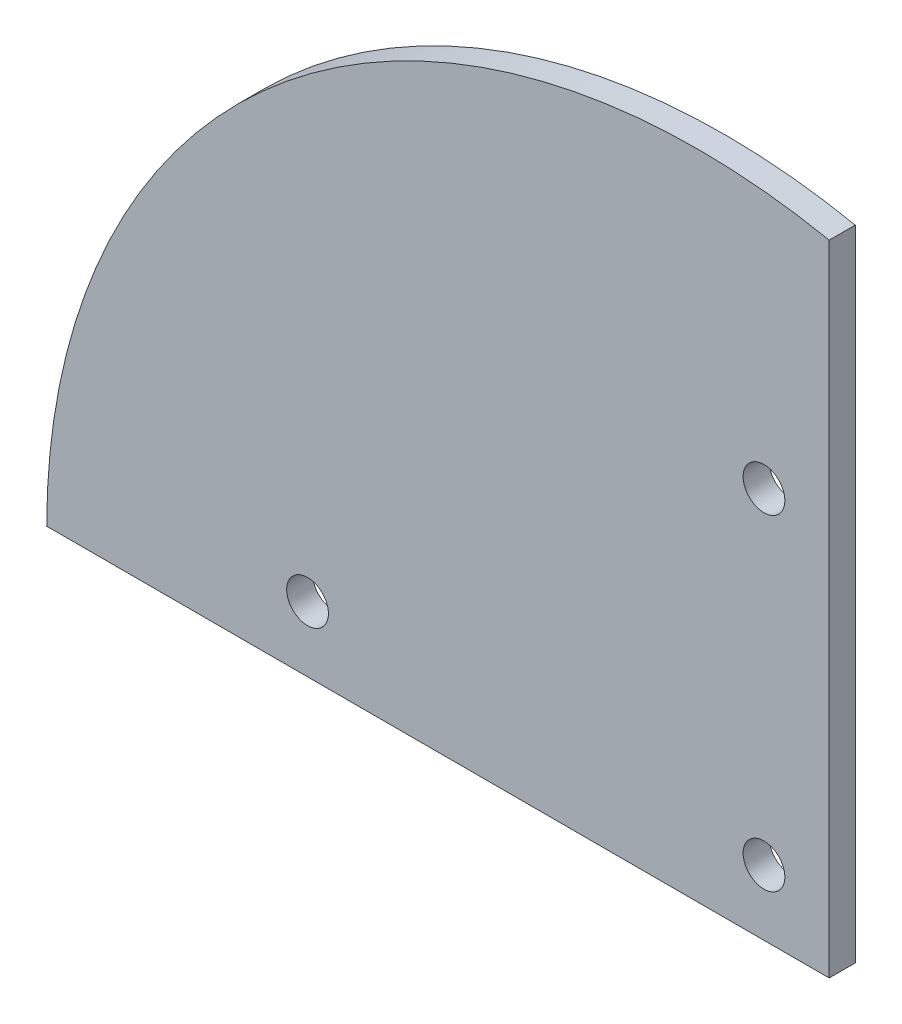
from build123d import *

# Parameters (mm, degrees)
MODEL_R                         = 1.6
AUFSATZ_LINEAR_AUSTRAGEN1_DEPTH = 2


with BuildPart() as part:
    # Model → Aufsatz-Linear austragen1 (new body)
    with BuildSketch(Plane.XY):
        with BuildLine():
            Line((60, 0), (60, 49))
            ThreePointArc((60, 49), (18.375108617, 38.734560877), (0, 0))
            Line((0, 0), (60, 0))
        make_face()
        with Locations((20, 5)):
            Circle(MODEL_R, mode=Mode.SUBTRACT)
        with Locations((55, 30)):
            Circle(MODEL_R, mode=Mode.SUBTRACT)
        with Locations((55, 5)):
            Circle(MODEL_R, mode=Mode.SUBTRACT)
    extrude(amount=AUFSATZ_LINEAR_AUSTRAGEN1_DEPTH)


solid = part.part
